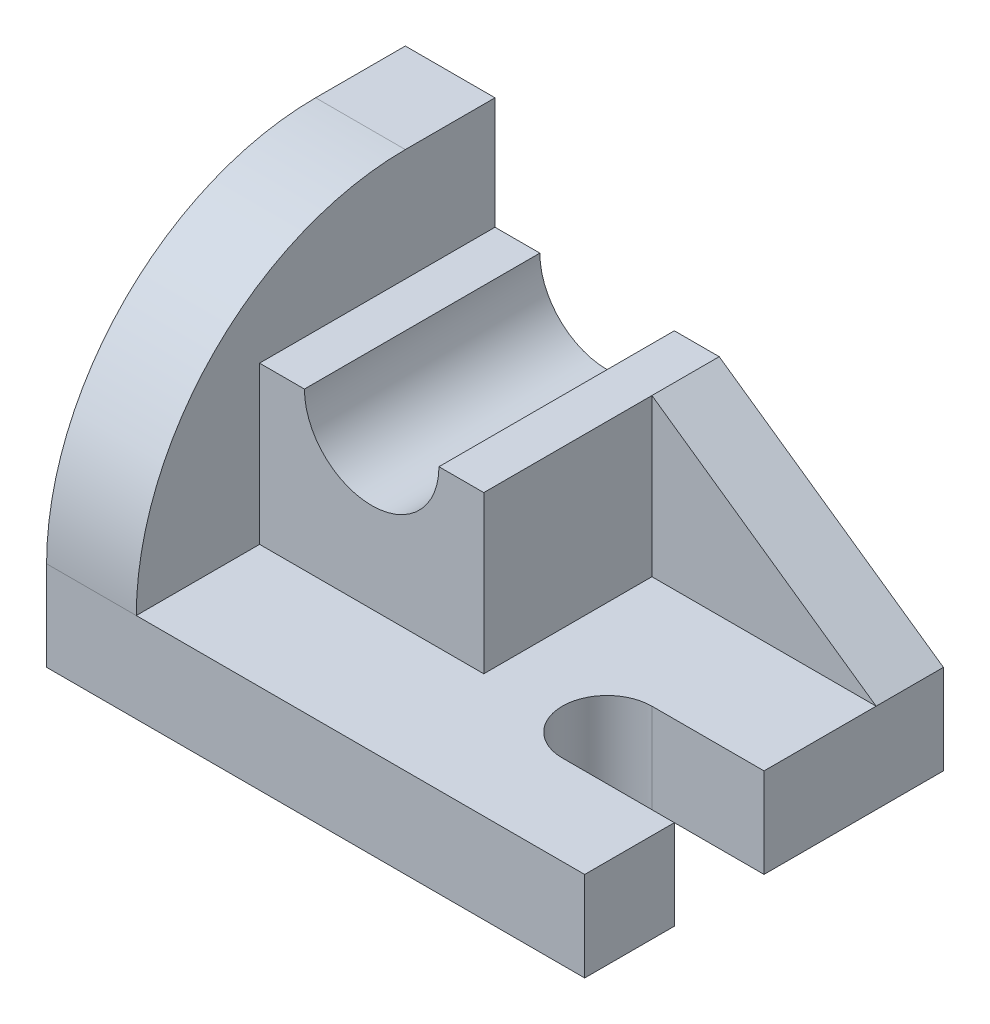
from build123d import *

# Parameters (mm, degrees)
BOSS_EXTRUDE3_DEPTH = 16
BOSS_EXTRUDE4_DEPTH = 16
BOSS_EXTRUDE5_DEPTH = 42
BOSS_EXTRUDE6_DEPTH = 12


with BuildPart() as part:
    # Sketch5 → Boss-Extrude3 (new body)
    with BuildSketch(Plane(origin=(0, 0, 0), x_dir=(1, 0, 0), z_dir=(0, 1, 0))):
        with BuildLine():
            Line((0, 0), (96, 0))
            Line((96, 0), (96, 16))
            Line((96, 16), (76, 16))
            ThreePointArc((76, 16), (68, 24), (76, 32))
            Line((76, 32), (96, 32))
            Line((96, 32), (96, 64))
            Line((96, 64), (0, 64))
            Line((0, 64), (0, 0))
        make_face()
    extrude(amount=BOSS_EXTRUDE3_DEPTH)

    # Sketch6 → Boss-Extrude4 (add)
    with BuildSketch(Plane.ZY):
        with BuildLine():
            Line((-64, 0), (-64, 64))
            Line((-64, 64), (-48, 64))
            ThreePointArc((-48, 64), (-14.058874503, 49.941125497), (0, 16))
            Line((0, 16), (0, 0))
            Line((0, 0), (-64, 0))
        make_face()
    extrude(amount=-BOSS_EXTRUDE4_DEPTH)

    # Sketch7 → Boss-Extrude5 (add)
    with BuildSketch(Plane(origin=(0, 0, -64), x_dir=(-1, 0, 0), z_dir=(0, 0, -1))):
        with BuildLine():
            Line((-56, 16), (-16, 16))
            Line((-16, 16), (-16, 44))
            Line((-16, 44), (-24, 44))
            ThreePointArc((-24, 44), (-36, 32), (-48, 44))
            Line((-48, 44), (-56, 44))
            Line((-56, 44), (-56, 16))
        make_face()
    extrude(amount=-BOSS_EXTRUDE5_DEPTH)

    # Sketch8 → Boss-Extrude6 (add)
    with BuildSketch(Plane(origin=(0, 0, -64), x_dir=(-1, 0, 0), z_dir=(0, 0, -1))):
        Polygon((-96, 16), (-56, 44), (-56, 16), align=None)
    extrude(amount=-BOSS_EXTRUDE6_DEPTH)


solid = part.part
